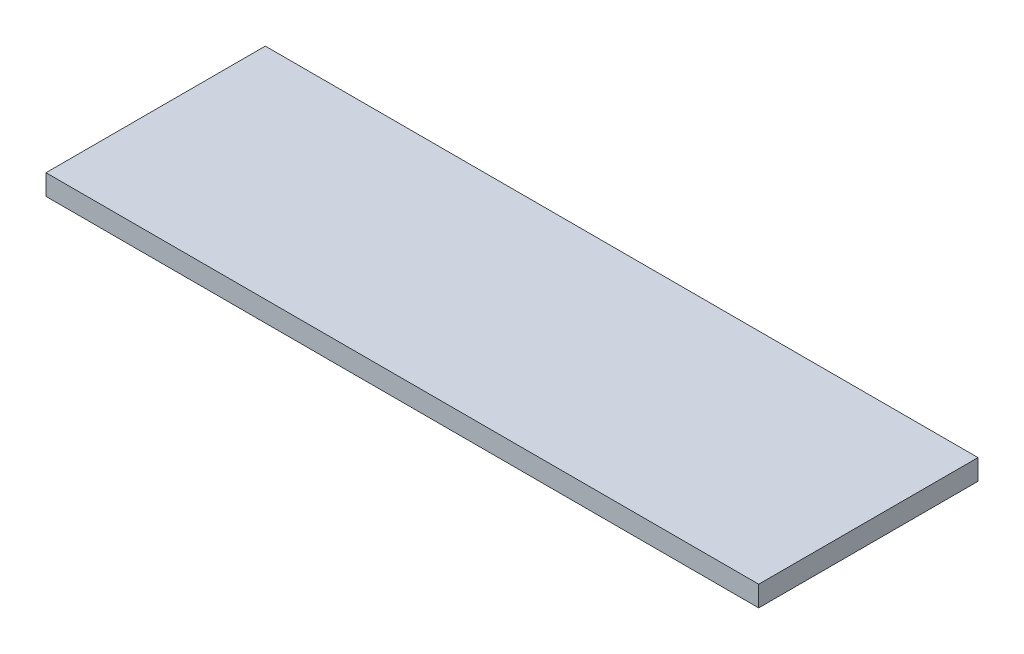
from build123d import *

# Parameters (mm, degrees)
SKETCH1_W           = 165.1
SKETCH1_H           = 50.8
BOSS_EXTRUDE1_DEPTH = 4.7625


with BuildPart() as part:
    # Sketch1 → Boss-Extrude1 (new body)
    with BuildSketch(Plane(origin=(0, 0, 0), x_dir=(1, 0, 0), z_dir=(0, 1, 0))):
        with Locations((82.55, -25.4)):
            Rectangle(SKETCH1_W, SKETCH1_H)
    extrude(amount=BOSS_EXTRUDE1_DEPTH)


solid = part.part
